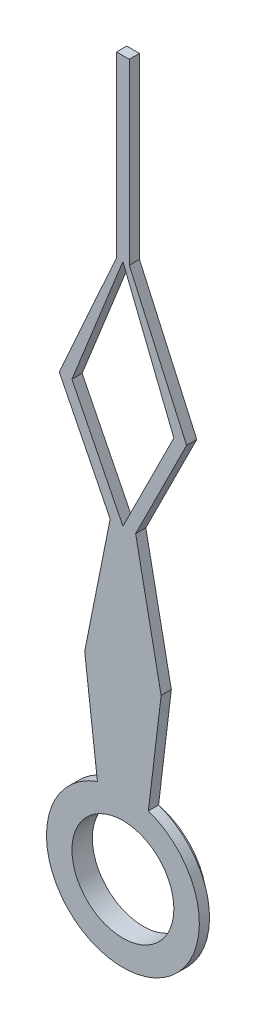
from build123d import *

# Parameters (mm, degrees)
CROQUIS1_R              = 1
SALIENTE_EXTRUIR1_DEPTH = 0.2
CROQUIS2_R              = 1.25
CROQUIS2_R_2            = 1
SALIENTE_EXTRUIR2_DEPTH = 0.2


with BuildPart() as part:
    # Croquis1 → Saliente-Extruir1 (new body)
    with BuildSketch(Plane.XY):
        with BuildLine():
            Line((0.5, 1.414213562), (0.75, 3.5))
            Line((0.75, 3.5), (0.25, 6))
            Line((0.25, 6), (1.25, 8))
            Line((1.25, 8), (0.125, 10.5))
            Line((0.125, 10.5), (0.125, 14))
            Line((0.125, 14), (-0.125, 14))
            Line((-0.125, 14), (-0.125, 10.5))
            Line((-0.125, 10.5), (-1.25, 8))
            Line((-1.25, 8), (-0.25, 6))
            Line((-0.25, 6), (-0.75, 3.5))
            Line((-0.75, 3.5), (-0.5, 1.414213562))
            ThreePointArc((-0.5, 1.414213562), (0, -1.5), (0.5, 1.414213562))
        make_face()
        Circle(CROQUIS1_R, mode=Mode.SUBTRACT)
        Polygon((0, 6), (1, 8), (0, 10.5), (-1, 8), align=None, mode=Mode.SUBTRACT)
    extrude(amount=SALIENTE_EXTRUIR1_DEPTH)

    # Croquis2 → Saliente-Extruir2 (add)
    with BuildSketch(Plane(origin=(0, 0, 0), x_dir=(-1, 0, 0), z_dir=(0, 0, -1))):
        Circle(CROQUIS2_R)
        Circle(CROQUIS2_R_2, mode=Mode.SUBTRACT)
    extrude(amount=SALIENTE_EXTRUIR2_DEPTH)


solid = part.part
